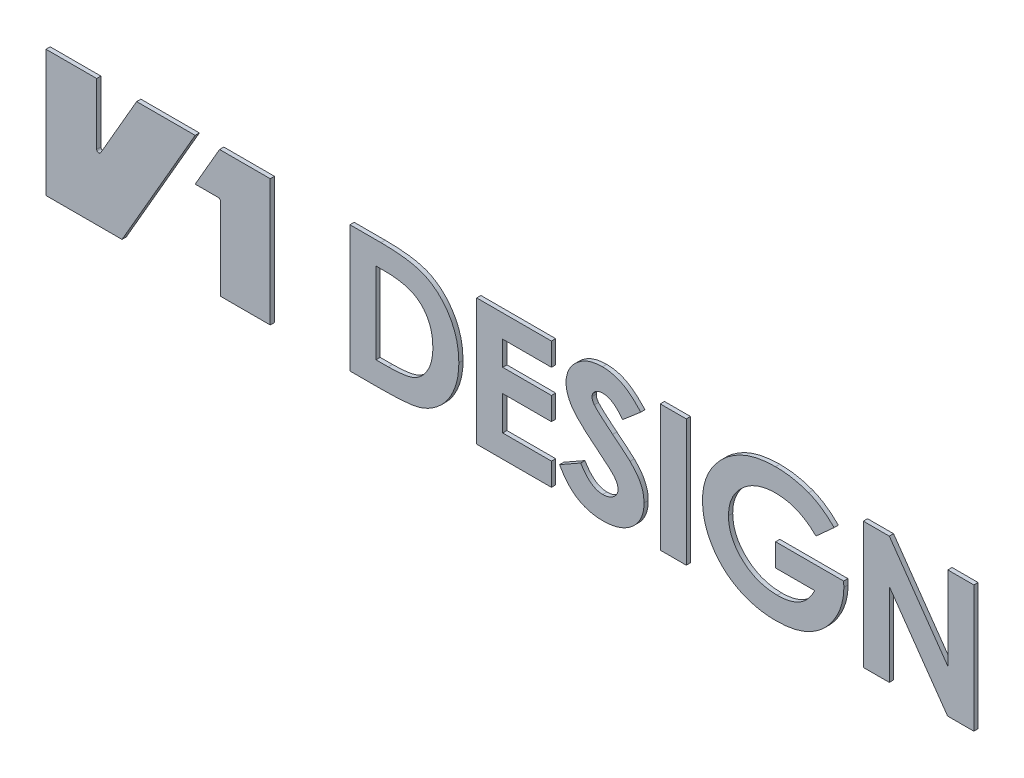
from build123d import *

# Parameters (mm, degrees)
BOSS_EXTRUDE1_DEPTH   = 1
BOSS_EXTRUDE1_2_DEPTH = 1
BOSS_EXTRUDE1_3_DEPTH = 1
BOSS_EXTRUDE1_4_DEPTH = 1
MODEL_W               = 6.153846154
MODEL_H               = 30
BOSS_EXTRUDE1_5_DEPTH = 1
BOSS_EXTRUDE1_6_DEPTH = 1
BOSS_EXTRUDE1_7_DEPTH = 1
BOSS_EXTRUDE1_8_DEPTH = 1


with BuildPart() as part:
    # Model → Boss-Extrude1 (new body)
    with BuildSketch(Plane.XY):
        with BuildLine():
            Line((53.094010768, 0), (53.094010768, 30))
            Line((53.094010768, 30), (41.094010768, 30))
            Line((41.094010768, 30), (35.320508076, 20))
            Line((35.320508076, 20), (40.820508076, 20))
            ThreePointArc((40.820508076, 20), (41.174061466, 19.853553391), (41.320508076, 19.5))
            Line((41.320508076, 19.5), (41.320508076, 0))
            Line((41.320508076, 0), (53.094010768, 0))
        make_face()
    extrude(amount=BOSS_EXTRUDE1_DEPTH)


with BuildPart() as body_2:
    # Model → Boss-Extrude1 2 (new body)
    with BuildSketch(Plane.XY):
        with BuildLine():
            Line((0, 30), (0, 0))
            Line((0, 0), (18, 0))
            Line((18, 0), (35.320508076, 30))
            Line((35.320508076, 30), (21.464101615, 30))
            Line((21.464101615, 30), (12.933012702, 15.223720558))
            ThreePointArc((12.933012702, 15.223720558), (12.370590477, 14.990757645), (12, 15.473720558))
            Line((12, 15.473720558), (12, 30))
            Line((12, 30), (0, 30))
        make_face()
    extrude(amount=BOSS_EXTRUDE1_2_DEPTH)


with BuildPart() as body_3:
    # Model → Boss-Extrude1 3 (new body)
    with BuildSketch(Plane.XY):
        Polygon((193.515143475, 30), (199.668989629, 30), (213.515143475, 10.258413462), (213.515143475, 30), (219.668989629, 30), (219.668989629, 0), (213.473076168, 0), (199.668989629, 19.681490385), (199.668989629, 0), (193.515143475, 0), align=None)
    extrude(amount=BOSS_EXTRUDE1_3_DEPTH)


with BuildPart() as body_4:
    # Model → Boss-Extrude1 4 (new body)
    with BuildSketch(Plane.XY):
        with BuildLine():
            Line((186.616105014, 25.228365385), (182.301201168, 21.328125))
            add(Edge.make_bspline(
                [(182.301201168, 21.328125), (181.958445843, 21.65132813), (181.284645204, 22.286692369), (180.189254832, 23.111077122), (179.056902568, 23.81166726), (177.881388558, 24.391062045), (176.659179757, 24.833679621), (175.395770657, 25.155892781), (174.089735062, 25.344365947), (173.205244083, 25.371096823), (172.757931937, 25.384615385)],
                knots=[0, 0, 0, 0, 0.132627556, 0.260723979, 0.385381028, 0.507275484, 0.629201284, 0.750872179, 0.874009003, 1, 1, 1, 1], degree=3))
            add(Edge.make_bspline(
                [(172.757931937, 25.384615385), (172.3689095, 25.375237941), (171.606373504, 25.356856897), (170.485571622, 25.216356079), (169.414116792, 24.981216803), (168.387258702, 24.659809864), (167.41416199, 24.231966637), (166.483894253, 23.724202944), (165.609657127, 23.108377005), (164.78675891, 22.419293443), (164.039016352, 21.661417434), (163.385647891, 20.851384669), (162.830334399, 20.002657181), (162.372603207, 19.11173937), (162.027787924, 18.177860913), (161.770690865, 17.206817272), (161.617862209, 16.194785726), (161.600737015, 15.505323682), (161.592066552, 15.15625)],
                knots=[0, 0, 0, 0, 0.069140469, 0.135524565, 0.200412416, 0.263928605, 0.326443717, 0.38908041, 0.452004917, 0.516200231, 0.579654503, 0.640939501, 0.700890977, 0.759655791, 0.818587594, 0.877492497, 0.93797462, 1, 1, 1, 1], degree=3))
            add(Edge.make_bspline(
                [(161.592066552, 15.15625), (161.602492413, 14.795069257), (161.623038576, 14.083293218), (161.784854243, 13.03829554), (162.040035522, 12.033074552), (162.413212122, 11.075278279), (162.874336944, 10.150931829), (163.459432642, 9.281548706), (164.134768009, 8.444351445), (164.914175683, 7.666144045), (165.762539691, 6.948011314), (166.678242612, 6.328047301), (167.634268728, 5.793081441), (168.646241627, 5.368291046), (169.701183802, 5.0283595), (170.806228707, 4.790130836), (171.958606538, 4.641719217), (172.743452582, 4.62426175), (173.142547321, 4.615384615)],
                knots=[0, 0, 0, 0, 0.062169985, 0.122517898, 0.181670881, 0.240417116, 0.29919474, 0.359182706, 0.420492115, 0.484156238, 0.548552584, 0.611605373, 0.674293815, 0.736892027, 0.800275162, 0.864892872, 0.931297935, 1, 1, 1, 1], degree=3))
            add(Edge.make_bspline(
                [(173.142547321, 4.615384615), (173.403131318, 4.617579563), (173.913182022, 4.621875814), (174.661293386, 4.692752119), (175.379101288, 4.79526739), (176.068383064, 4.926462326), (176.722246255, 5.119815622), (177.348597739, 5.338828801), (177.944415765, 5.602498277), (178.507118074, 5.913391695), (179.04486056, 6.260394509), (179.549557515, 6.659162146), (180.027575538, 7.103191876), (180.48527574, 7.587965288), (180.910629764, 8.124548188), (181.308668691, 8.705671054), (181.683135841, 9.331444878), (181.905365319, 9.774134752), (182.018749245, 10)],
                knots=[0, 0, 0, 0, 0.07073225, 0.138446851, 0.203834004, 0.267627003, 0.328745716, 0.388789946, 0.44772003, 0.505414577, 0.563198802, 0.621307265, 0.679816603, 0.740234179, 0.802163243, 0.865532765, 0.931393336, 1, 1, 1, 1], degree=3))
            Line((182.018749245, 10), (172.745912706, 10))
            Line((172.745912706, 10), (172.745912706, 15.384615385))
            Line((172.745912706, 15.384615385), (188.857691552, 15.384615385))
            Line((188.857691552, 15.384615385), (188.89975886, 14.104567308))
            add(Edge.make_bspline(
                [(188.89975886, 14.104567308), (188.892411007, 13.775776459), (188.877725403, 13.118646774), (188.772065012, 12.140840491), (188.60592439, 11.17406815), (188.362152506, 10.223264594), (188.056634792, 9.28231497), (187.676679155, 8.35741607), (187.227682105, 7.445861414), (186.722068532, 6.551601623), (186.160324423, 5.690230598), (185.550578511, 4.876548587), (184.902729296, 4.111496059), (184.210042889, 3.402768003), (183.481238851, 2.744103459), (182.710266035, 2.141179888), (181.895831096, 1.596368535), (181.049047894, 1.092832968), (180.157905789, 0.655471295), (179.227591058, 0.276014605), (178.26222989, -0.047745069), (177.25878383, -0.313641349), (176.216831347, -0.51801617), (175.136658703, -0.657847604), (174.019647864, -0.753304083), (173.26294518, -0.763861697), (172.878124245, -0.769230769)],
                knots=[0, 0, 0, 0, 0.040453193, 0.080850772, 0.120890288, 0.161066153, 0.201523101, 0.242537917, 0.283988932, 0.326488003, 0.368877557, 0.410437637, 0.451532375, 0.492148214, 0.532292306, 0.572331822, 0.612463803, 0.652795146, 0.693473769, 0.734488585, 0.776348038, 0.818680216, 0.862140638, 0.906903463, 0.952655782, 1, 1, 1, 1], degree=3))
            add(Edge.make_bspline(
                [(172.878124245, -0.769230769), (172.465279441, -0.764015208), (171.650452253, -0.753721313), (170.446393023, -0.655351764), (169.277130035, -0.492196553), (168.141259908, -0.270788447), (167.036787356, 0.011512225), (165.966219424, 0.359241434), (164.93166327, 0.775878964), (163.933125784, 1.249634927), (162.978995804, 1.78299448), (162.074219967, 2.374466274), (161.218985798, 3.018939039), (160.411793158, 3.715609317), (159.66096866, 4.468856802), (158.958170959, 5.272354307), (158.310631112, 6.133965848), (157.711529877, 7.041495724), (157.178698664, 7.988072539), (156.716401288, 8.959090988), (156.314572956, 9.943912644), (155.999959986, 10.952715359), (155.741550756, 11.974664154), (155.572925181, 13.018549416), (155.458065002, 14.077964557), (155.444862245, 14.791357358), (155.438220398, 15.150240385)],
                knots=[0, 0, 0, 0, 0.046942493, 0.092649876, 0.137270808, 0.181144023, 0.224186077, 0.266834469, 0.309052969, 0.350933301, 0.392443342, 0.433261238, 0.473765796, 0.514141382, 0.554412719, 0.594616344, 0.635439961, 0.676888696, 0.718200101, 0.758856205, 0.799128831, 0.839042907, 0.878934874, 0.91889573, 0.959199272, 1, 1, 1, 1], degree=3))
            add(Edge.make_bspline(
                [(155.438220398, 15.150240385), (155.450573739, 15.639707202), (155.474979397, 16.60671359), (155.679719449, 18.031817093), (156.009717455, 19.408721627), (156.472933768, 20.736657867), (157.076077238, 22.011216568), (157.796743013, 23.243242762), (158.662149996, 24.422697175), (159.325627922, 25.152010015), (159.662980014, 25.522836538)],
                knots=[0, 0, 0, 0, 0.127753405, 0.252393736, 0.375069467, 0.496984605, 0.618891888, 0.742685384, 0.869165769, 1, 1, 1, 1], degree=3))
            add(Edge.make_bspline(
                [(159.662980014, 25.522836538), (159.872975622, 25.737598375), (160.290281742, 26.164376006), (160.954228237, 26.758218573), (161.639903559, 27.315088974), (162.35419679, 27.820906173), (163.086182441, 28.295392938), (163.842276342, 28.727273253), (164.624729991, 29.118458074), (165.431286133, 29.467402636), (166.260151709, 29.773459453), (167.113210196, 30.037781081), (167.988143034, 30.269360261), (168.890650333, 30.444196739), (169.812110225, 30.592491136), (170.759163754, 30.690560624), (171.729181759, 30.762396987), (172.38519756, 30.766940563), (172.715864629, 30.769230769)],
                knots=[0, 0, 0, 0, 0.062203969, 0.123612571, 0.184399765, 0.245082062, 0.304819213, 0.365037226, 0.425348096, 0.485936684, 0.54698533, 0.608276054, 0.670877355, 0.734352714, 0.798616617, 0.864144788, 0.931521703, 1, 1, 1, 1], degree=3))
            add(Edge.make_bspline(
                [(172.715864629, 30.769230769), (173.06252715, 30.764237684), (173.752461015, 30.754300357), (174.776972854, 30.686132679), (175.786122904, 30.580169081), (176.776127726, 30.421637276), (177.751909608, 30.226250479), (178.7089744, 29.975675205), (179.651298646, 29.692352293), (180.265048622, 29.464389092), (180.570431937, 29.350961538)],
                knots=[0, 0, 0, 0, 0.129555692, 0.257844025, 0.383597204, 0.508653116, 0.632429557, 0.755363099, 0.878276121, 1, 1, 1, 1], degree=3))
            add(Edge.make_bspline(
                [(180.570431937, 29.350961538), (180.82839912, 29.24628678), (181.352102542, 29.033784831), (182.116123622, 28.646429623), (182.878659398, 28.208758898), (183.642353321, 27.727225346), (184.391144243, 27.173294687), (185.144467502, 26.580382876), (185.890864122, 25.930797477), (186.37180595, 25.464981252), (186.616105014, 25.228365385)],
                knots=[0, 0, 0, 0, 0.113310259, 0.230033021, 0.348397057, 0.471256297, 0.597364704, 0.727420466, 0.861540583, 1, 1, 1, 1], degree=3))
        make_face()
    extrude(amount=BOSS_EXTRUDE1_4_DEPTH)


with BuildPart() as body_5:
    # Model → Boss-Extrude1 5 (new body)
    with BuildSketch(Plane.XY):
        with Locations((148.515143475, 15)):
            Rectangle(MODEL_W, MODEL_H)
    extrude(amount=BOSS_EXTRUDE1_5_DEPTH)


with BuildPart() as body_6:
    # Model → Boss-Extrude1 6 (new body)
    with BuildSketch(Plane.XY):
        with BuildLine():
            Line((140.822835783, 25.991586538), (136.513941552, 22.307692308))
            add(Edge.make_bspline(
                [(136.513941552, 22.307692308), (136.327164488, 22.550975117), (135.968491523, 23.01815757), (135.395571973, 23.644988642), (134.824388808, 24.180523502), (134.245438403, 24.618074239), (133.660483994, 24.958750132), (133.072875703, 25.202495295), (132.481341124, 25.356553645), (132.083736559, 25.375311903), (131.886537706, 25.384615385)],
                knots=[0, 0, 0, 0, 0.159664839, 0.306608639, 0.441698598, 0.566883148, 0.683726719, 0.793183689, 0.897425878, 1, 1, 1, 1], degree=3))
            add(Edge.make_bspline(
                [(131.886537706, 25.384615385), (131.7035804, 25.378845405), (131.351759381, 25.36774992), (130.848975209, 25.250357062), (130.39871039, 25.057563545), (130.00905718, 24.793755027), (129.69564289, 24.485073707), (129.451842012, 24.155203893), (129.316281176, 23.791823994), (129.294927217, 23.542623992), (129.284374245, 23.419471154)],
                knots=[0, 0, 0, 0, 0.152184912, 0.292646694, 0.427184681, 0.558167355, 0.682070475, 0.792257762, 0.897335289, 1, 1, 1, 1], degree=3))
            add(Edge.make_bspline(
                [(129.284374245, 23.419471154), (129.292424152, 23.29474443), (129.308623968, 23.043741524), (129.406613764, 22.671727257), (129.578495793, 22.314171256), (129.733741918, 22.095250088), (129.813220398, 21.983173077)],
                knots=[0, 0, 0, 0, 0.240346939, 0.483679668, 0.735669055, 1, 1, 1, 1], degree=3))
            add(Edge.make_bspline(
                [(129.813220398, 21.983173077), (129.888434411, 21.896197823), (130.060967256, 21.696685957), (130.381367123, 21.377264544), (130.786409704, 20.988749265), (131.288706029, 20.539598263), (131.875650753, 20.022404127), (132.559898532, 19.445059626), (133.330117478, 18.79879693), (133.877310498, 18.348863101), (134.164181937, 18.112980769)],
                knots=[0, 0, 0, 0, 0.059167547, 0.13572398, 0.232715729, 0.348057276, 0.482492215, 0.635372306, 0.808840267, 1, 1, 1, 1], degree=3))
            add(Edge.make_bspline(
                [(134.164181937, 18.112980769), (134.432232956, 17.894169321), (134.941914045, 17.478113984), (135.671212302, 16.894654804), (136.30592591, 16.360159637), (136.867646437, 15.903538923), (137.334585079, 15.496006953), (137.72758158, 15.162495119), (138.033550744, 14.887244277), (138.206938874, 14.721862682), (138.280768475, 14.651442308)],
                knots=[0, 0, 0, 0, 0.19295945, 0.366899491, 0.520798768, 0.655675628, 0.770540595, 0.866382819, 0.943105084, 1, 1, 1, 1], degree=3))
            add(Edge.make_bspline(
                [(138.280768475, 14.651442308), (138.564156693, 14.36547836), (139.107130229, 13.81756971), (139.809065254, 12.959110965), (140.399288101, 12.131940971), (140.844339932, 11.299141524), (141.179588575, 10.461902923), (141.426466027, 9.599349488), (141.562769388, 8.696282664), (141.582227863, 8.081355282), (141.592066552, 7.770432692)],
                knots=[0, 0, 0, 0, 0.153397482, 0.293910503, 0.422292483, 0.54017094, 0.652913129, 0.765577695, 0.881470248, 1, 1, 1, 1], degree=3))
            add(Edge.make_bspline(
                [(141.592066552, 7.770432692), (141.584374184, 7.467482428), (141.569276404, 6.872883191), (141.438676203, 6.000930492), (141.230824913, 5.170271878), (140.934258559, 4.378671338), (140.543722911, 3.633353945), (140.08423079, 2.917069375), (139.521078605, 2.257369329), (138.89568928, 1.630948382), (138.193304217, 1.0716928), (137.439794477, 0.573283816), (136.63070046, 0.159043791), (135.768937432, -0.180117391), (134.856559257, -0.440941787), (133.89448425, -0.635139203), (132.88097647, -0.750918754), (132.187323497, -0.763033086), (131.832451168, -0.769230769)],
                knots=[0, 0, 0, 0, 0.062485414, 0.122639865, 0.181490576, 0.238918809, 0.296600878, 0.354844533, 0.41412196, 0.475212197, 0.537251648, 0.599048251, 0.661351549, 0.724449246, 0.789860536, 0.856903731, 0.926792058, 1, 1, 1, 1], degree=3))
            add(Edge.make_bspline(
                [(131.832451168, -0.769230769), (131.553847682, -0.764723562), (131.003703607, -0.755823409), (130.192771731, -0.682009583), (129.409685456, -0.563048376), (128.654750144, -0.394009826), (127.925790976, -0.177374656), (127.222220364, 0.086225105), (126.547213405, 0.399619891), (125.899500376, 0.762051375), (125.279037413, 1.178620282), (124.682319634, 1.648742539), (124.110803497, 2.175779283), (123.554760382, 2.752413735), (123.030090949, 3.391197103), (122.520843719, 4.078807426), (122.041287662, 4.82598299), (121.743819531, 5.351101741), (121.592066552, 5.618990385)],
                knots=[0, 0, 0, 0, 0.065468645, 0.129277589, 0.191201995, 0.25151068, 0.310945655, 0.369795974, 0.427931986, 0.48568739, 0.544055514, 0.603393446, 0.664041147, 0.726641954, 0.791503442, 0.858171476, 0.927646364, 1, 1, 1, 1], degree=3))
            Line((121.592066552, 5.618990385), (126.604085783, 8.461538462))
            add(Edge.make_bspline(
                [(126.604085783, 8.461538462), (126.790941325, 8.157392651), (127.149881828, 7.573143186), (127.753877658, 6.789978134), (128.372514941, 6.12210567), (129.012713664, 5.572434756), (129.67914234, 5.143957853), (130.370486356, 4.840729526), (131.08308521, 4.649874337), (131.566883578, 4.626869458), (131.808412706, 4.615384615)],
                knots=[0, 0, 0, 0, 0.157892435, 0.303303769, 0.436908281, 0.560191917, 0.675788922, 0.786154063, 0.893240601, 1, 1, 1, 1], degree=3))
            add(Edge.make_bspline(
                [(131.808412706, 4.615384615), (132.055833561, 4.624903427), (132.536335167, 4.643389356), (133.222692026, 4.81139507), (133.851759485, 5.075799317), (134.394946368, 5.454920422), (134.85238105, 5.892657206), (135.193890189, 6.377547766), (135.399636843, 6.907613335), (135.42531988, 7.2739319), (135.438220398, 7.457932692)],
                knots=[0, 0, 0, 0, 0.145479038, 0.28252635, 0.413563185, 0.545092869, 0.670219766, 0.784738488, 0.891874743, 1, 1, 1, 1], degree=3))
            add(Edge.make_bspline(
                [(135.438220398, 7.457932692), (135.429193363, 7.629314364), (135.410798345, 7.978550688), (135.247947098, 8.495913097), (134.998012237, 9.011280548), (134.709970879, 9.435245843), (134.416858657, 9.792762881), (134.125925381, 10.093918112), (133.785217143, 10.438606063), (133.37917873, 10.810083837), (132.916377097, 11.216422416), (132.400491373, 11.665192033), (131.815697867, 12.135028374), (131.407799106, 12.46198555), (131.195431937, 12.632211538)],
                knots=[0, 0, 0, 0, 0.074366882, 0.151542555, 0.233745418, 0.322891422, 0.373637387, 0.434642341, 0.504858238, 0.58437273, 0.673854294, 0.772679702, 0.881648652, 1, 1, 1, 1], degree=3))
            add(Edge.make_bspline(
                [(131.195431937, 12.632211538), (130.787404876, 12.955022819), (130.00563772, 13.573519191), (128.902652382, 14.490465031), (127.910167824, 15.349225474), (127.026913154, 16.149151306), (126.262177795, 16.897743974), (125.602517498, 17.579679574), (125.059460367, 18.208957471), (124.496667276, 18.958613528), (123.953699324, 19.866463675), (123.485671661, 20.963750854), (123.181772697, 22.061021618), (123.147410887, 22.798645214), (123.130528091, 23.161057692)],
                knots=[0, 0, 0, 0, 0.113807495, 0.218051619, 0.313729385, 0.400891109, 0.478669682, 0.547784192, 0.608383958, 0.660354295, 0.7527143, 0.838906823, 0.92085099, 1, 1, 1, 1], degree=3))
            add(Edge.make_bspline(
                [(123.130528091, 23.161057692), (123.136057479, 23.418024497), (123.146964143, 23.924888963), (123.275869606, 24.669204513), (123.464535656, 25.387805752), (123.73755184, 26.077380605), (124.090350464, 26.737092149), (124.51845586, 27.370237936), (125.027313173, 27.972998998), (125.607113953, 28.540229107), (126.245018049, 29.05588639), (126.920197704, 29.520106023), (127.639963338, 29.902975868), (128.391299881, 30.223110894), (129.179983337, 30.471991039), (130.005330581, 30.644498848), (130.86828266, 30.747854414), (131.455563162, 30.762022924), (131.754326168, 30.769230769)],
                knots=[0, 0, 0, 0, 0.060194939, 0.118733919, 0.176620887, 0.234194413, 0.292195632, 0.351738162, 0.413087799, 0.476867605, 0.541649825, 0.605232111, 0.668704978, 0.732484784, 0.796518388, 0.862301165, 0.929949458, 1, 1, 1, 1], degree=3))
            add(Edge.make_bspline(
                [(131.754326168, 30.769230769), (132.141753472, 30.756322939), (132.911378755, 30.730681502), (134.048510074, 30.530653901), (135.157701298, 30.211120282), (136.056788626, 29.834724098), (136.769588925, 29.457492584), (137.321294958, 29.122920218), (137.878486464, 28.727388228), (138.453914011, 28.291459875), (139.026494693, 27.78568348), (139.62375271, 27.243067826), (140.224667091, 26.638930939), (140.619884155, 26.211222908), (140.822835783, 25.991586538)],
                knots=[0, 0, 0, 0, 0.109692733, 0.217904881, 0.326012838, 0.436139141, 0.493250307, 0.554364954, 0.618748228, 0.686731612, 0.758742253, 0.835044889, 0.915292351, 1, 1, 1, 1], degree=3))
        make_face()
    extrude(amount=BOSS_EXTRUDE1_6_DEPTH)


with BuildPart() as body_7:
    # Model → Boss-Extrude1 7 (new body)
    with BuildSketch(Plane.XY):
        Polygon((101.976681937, 30), (119.668989629, 30), (119.668989629, 24.615384615), (108.130528091, 24.615384615), (108.130528091, 18.846153846), (119.668989629, 18.846153846), (119.668989629, 13.461538462), (108.130528091, 13.461538462), (108.130528091, 5.384615385), (119.668989629, 5.384615385), (119.668989629, 0), (101.976681937, 0), align=None)
    extrude(amount=BOSS_EXTRUDE1_7_DEPTH)


with BuildPart() as body_8:
    # Model → Boss-Extrude1 8 (new body)
    with BuildSketch(Plane.XY):
        with BuildLine():
            Line((71.976681937, 30), (79.308412706, 30))
            add(Edge.make_bspline(
                [(79.308412706, 30), (79.879424958, 29.996228217), (80.985966494, 29.988919031), (82.587509326, 29.909107229), (84.077002625, 29.784498309), (85.451669453, 29.615139959), (86.714005009, 29.387653377), (87.860804655, 29.108591471), (88.895512919, 28.778213618), (89.830409976, 28.398519644), (90.683343742, 27.947963764), (91.493194251, 27.449538399), (92.261767683, 26.883408983), (92.993251013, 26.254885373), (93.685392392, 25.561038169), (94.340266406, 24.80401886), (94.952905703, 23.982237449), (95.53021101, 23.108452806), (96.051446164, 22.182035028), (96.503022278, 21.208773398), (96.888902387, 20.199311762), (97.200517912, 19.147915733), (97.447944413, 18.060219097), (97.620897195, 16.933626872), (97.724472049, 15.769182066), (97.738689497, 14.980180907), (97.745912706, 14.579326923)],
                knots=[0, 0, 0, 0, 0.062253274, 0.120638101, 0.174780253, 0.22519584, 0.271592122, 0.314553077, 0.353785681, 0.389924623, 0.424409366, 0.458835961, 0.493521393, 0.528369419, 0.563890601, 0.600278822, 0.637408698, 0.675572549, 0.714394457, 0.753186863, 0.792452283, 0.832116592, 0.872650525, 0.913981603, 0.956298141, 1, 1, 1, 1], degree=3))
            add(Edge.make_bspline(
                [(97.745912706, 14.579326923), (97.731402185, 14.013583849), (97.702818442, 12.899147371), (97.461815055, 11.264025784), (97.072662311, 9.696355922), (96.523603378, 8.21071509), (95.850985902, 6.814571204), (95.040517027, 5.540934552), (94.1157597, 4.387408013), (93.077405224, 3.371348661), (91.960298333, 2.489482862), (90.790763752, 1.74301589), (89.569097442, 1.148784625), (88.49441905, 0.77688767), (87.561562565, 0.540593325), (86.742581618, 0.405242746), (85.809148388, 0.276448741), (84.756134843, 0.179940982), (83.586386435, 0.092269181), (82.29947641, 0.044915897), (80.897199074, 0.005406917), (79.923432474, 0.001850907), (79.416585783, 0)],
                knots=[0, 0, 0, 0, 0.062997712, 0.124096877, 0.183687473, 0.242639092, 0.300226692, 0.356006212, 0.410444696, 0.464571256, 0.517476919, 0.568737989, 0.618841069, 0.668455225, 0.695138378, 0.725956971, 0.760862657, 0.800099341, 0.843727382, 0.891525654, 0.943538972, 1, 1, 1, 1], degree=3))
            Line((79.416585783, 0), (71.976681937, 0))
            Line((71.976681937, 0), (71.976681937, 30))
        make_face()
        with BuildLine():
            Line((78.130528091, 24.615384615), (78.130528091, 5.384615385))
            Line((78.130528091, 5.384615385), (81.021153091, 5.384615385))
            add(Edge.make_bspline(
                [(81.021153091, 5.384615385), (81.365809365, 5.385250594), (82.029453776, 5.386473707), (82.986775076, 5.442427737), (83.872085338, 5.49902856), (84.683099826, 5.606288348), (85.42571184, 5.724529055), (86.089494792, 5.891582248), (86.686648141, 6.064377377), (87.211034048, 6.287093747), (87.69133816, 6.538595433), (88.140922141, 6.827291177), (88.570995087, 7.154712756), (88.978851636, 7.518760848), (89.357675601, 7.927111054), (89.721597341, 8.365296231), (90.05711886, 8.850143802), (90.373350332, 9.369128391), (90.665971558, 9.921994024), (90.907813803, 10.511749147), (91.120980042, 11.129126368), (91.295225222, 11.77742614), (91.425499166, 12.458754316), (91.521083177, 13.170944615), (91.583601507, 13.913145432), (91.58921793, 14.418942848), (91.592066552, 14.675480769)],
                knots=[0, 0, 0, 0, 0.063486238, 0.122244364, 0.176650972, 0.226870418, 0.272924284, 0.31508685, 0.35291361, 0.387323371, 0.419846514, 0.452711314, 0.485634092, 0.519350007, 0.55329343, 0.588169151, 0.624210821, 0.661810022, 0.700109188, 0.739316996, 0.779117904, 0.820390675, 0.862879908, 0.906830011, 0.952744648, 1, 1, 1, 1], degree=3))
            add(Edge.make_bspline(
                [(91.592066552, 14.675480769), (91.582174217, 15.068451121), (91.562886761, 15.834640094), (91.432099243, 16.951896922), (91.203541355, 18.002356026), (90.885793891, 18.985695011), (90.478522913, 19.902566762), (89.963643359, 20.740086107), (89.380492305, 21.528116654), (88.912414684, 21.983100811), (88.677403091, 22.211538462)],
                knots=[0, 0, 0, 0, 0.141599176, 0.276081202, 0.404642362, 0.528366463, 0.647907361, 0.765141984, 0.882082898, 1, 1, 1, 1], degree=3))
            add(Edge.make_bspline(
                [(88.677403091, 22.211538462), (88.445965872, 22.406623546), (87.974324376, 22.804183721), (87.154774123, 23.285340948), (86.248358188, 23.704479426), (85.236731911, 24.036147723), (84.129369277, 24.300439344), (82.920984772, 24.48114705), (81.616424886, 24.598305288), (80.712933681, 24.609564598), (80.245912706, 24.615384615)],
                knots=[0, 0, 0, 0, 0.101171352, 0.20617517, 0.31689931, 0.435020366, 0.561891964, 0.69761598, 0.843695568, 1, 1, 1, 1], degree=3))
            Line((80.245912706, 24.615384615), (78.130528091, 24.615384615))
        make_face(mode=Mode.SUBTRACT)
    extrude(amount=BOSS_EXTRUDE1_8_DEPTH)


solid = Compound([part.part, body_2.part, body_3.part, body_4.part, body_5.part, body_6.part, body_7.part, body_8.part])
